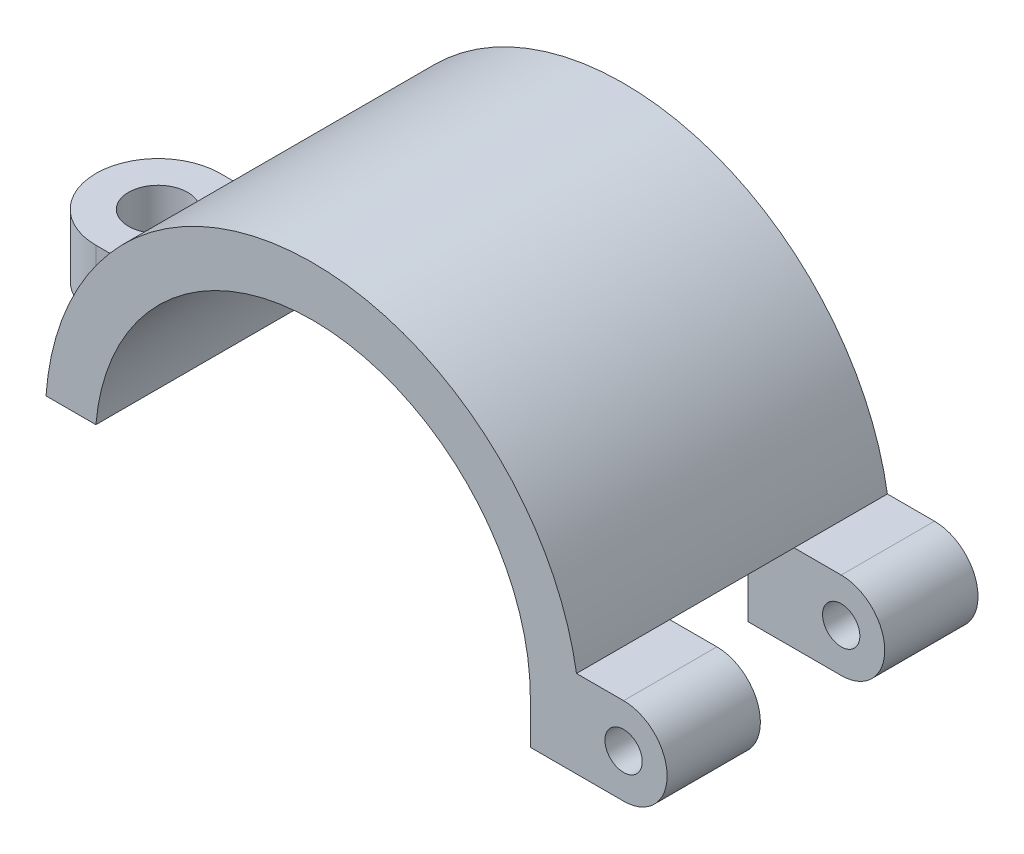
from build123d import *

# Parameters (mm, degrees)
BOSS_EXTRU_1_DEPTH      = 25
ESQUISSE2_R             = 2.375
BOSS_EXTRU_2_DEPTH      = 5
ESQUISSE3_R             = 1.5
BOSS_EXTRU_3_DEPTH      = 7.5
ESQUISSE4_R             = 1.5
BOSS_EXTRU_4_DEPTH      = 7.5
ESQUISSE5_W             = 11.114887109
ESQUISSE5_H             = 10.09418398
ENL_V_MAT_EXTRU_1_DEPTH = 10


with BuildPart() as part:
    # Esquisse1 → Boss.-Extru.1 (new body)
    with BuildSketch(Plane.XY):
        with BuildLine():
            Line((-17.435595774, 1.5), (-21.44761059, 1.5))
            ThreePointArc((-21.44761059, 1.5), (0.750457302, 21.486898656), (21.5, 0))
            Line((21.5, 0), (17.5, 0))
            ThreePointArc((17.5, 0), (0.750690999, 17.48389153), (-17.435595774, 1.5))
        make_face()
    extrude(amount=BOSS_EXTRU_1_DEPTH)

    # Esquisse2 → Boss.-Extru.2 (add)
    with BuildSketch(Plane.XZ.offset(-1.5)):
        with BuildLine():
            Line((-17.435595774, 7.5), (-24.935595774, 7.5))
            ThreePointArc((-24.935595774, 7.5), (-29.935595774, 12.5), (-24.935595774, 17.5))
            Line((-24.935595774, 17.5), (-17.435595774, 17.5))
            Line((-17.435595774, 17.5), (-17.435595774, 7.5))
        make_face()
        with Locations((-24.935595774, 12.5)):
            Circle(ESQUISSE2_R, mode=Mode.SUBTRACT)
    extrude(amount=-BOSS_EXTRU_2_DEPTH)

    # Esquisse3 → Boss.-Extru.3 (add)
    with BuildSketch(Plane.XY.offset(25)):
        with BuildLine():
            Line((17.5, -3.5), (25, -3.5))
            ThreePointArc((25, -3.5), (28.5, 0), (25, 3.5))
            Line((25, 3.5), (17.5, 3.5))
            Line((17.5, 3.5), (17.5, -3.5))
        make_face()
        with Locations((25, 0)):
            Circle(ESQUISSE3_R, mode=Mode.SUBTRACT)
    extrude(amount=-BOSS_EXTRU_3_DEPTH)

    # Esquisse4 → Boss.-Extru.4 (add)
    with BuildSketch(Plane(origin=(0, 0, 0), x_dir=(-1, 0, 0), z_dir=(0, 0, -1))):
        with BuildLine():
            Line((-17.5, -3.5), (-25, -3.5))
            ThreePointArc((-25, -3.5), (-28.5, 0), (-25, 3.5))
            Line((-25, 3.5), (-17.5, 3.5))
            Line((-17.5, 3.5), (-17.5, -3.5))
        make_face()
        with Locations((-25, 0)):
            Circle(ESQUISSE4_R, mode=Mode.SUBTRACT)
    extrude(amount=-BOSS_EXTRU_4_DEPTH)

    # Esquisse5 → Enlèv. mat.-Extru.1 (cut)
    with BuildSketch(Plane(origin=(0, 0, 17.5), x_dir=(-1, 0, 0), z_dir=(0, 0, -1))):
        with Locations((-19.442556445, -1.54709199)):
            Rectangle(ESQUISSE5_W, ESQUISSE5_H)
    extrude(amount=ENL_V_MAT_EXTRU_1_DEPTH, mode=Mode.SUBTRACT)


solid = part.part
